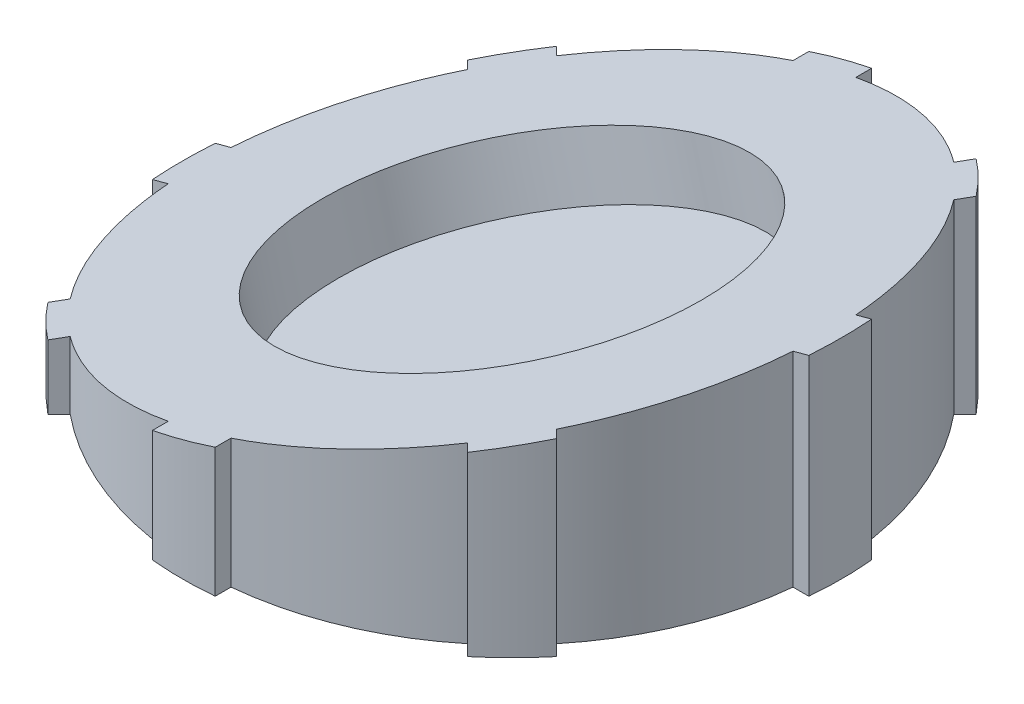
from build123d import *

# Parameters (mm, degrees)
SKETCH_1_R               = 20
EXTRUDE_1_DEPTH          = 20
EXTRUDE_2_DEPTH          = 20
PATTERN_CIRCULAR_1_COUNT = 8
CUT_EXTRUDE_1_DEPTH      = 34
SKETCH_5_R               = 12.5
CUT_EXTRUDE_2_DEPTH      = 4


with BuildPart() as part:
    # 草图1 → 凸台-拉伸1 (new body)
    with BuildSketch(Plane(origin=(0, 0, 0), x_dir=(1, 0, 0), z_dir=(0, 1, 0))):
        Circle(SKETCH_1_R)
    extrude(amount=EXTRUDE_1_DEPTH)

    # 草图3 → 凸台-拉伸2 (add)
    with BuildSketch(Plane(origin=(0, 20, 0), x_dir=(1, 0, 0), z_dir=(0, 1, 0))):
        with BuildLine():
            Line((-2, -20.90454496), (-2, 20.90454496))
            ThreePointArc((-2, 20.90454496), (0, 21), (2, 20.90454496))
            Line((2, 20.90454496), (2, -20.90454496))
            ThreePointArc((2, -20.90454496), (0, -21), (-2, -20.90454496))
        make_face()
    extrude_2 = extrude(amount=-EXTRUDE_2_DEPTH)

    # 阵列(圆周)1: 凸台-拉伸2 ×8 about axis
    pattern_circular_1_axis = Axis((0, 20, 0), (0, -1, 0))
    for i in range(1, PATTERN_CIRCULAR_1_COUNT):
        add(extrude_2.rotate(pattern_circular_1_axis, i * 360 / PATTERN_CIRCULAR_1_COUNT))

    # 草图2 → 切除-拉伸1 (cut, symmetric)
    with BuildSketch(Plane.XY):
        Polygon((-21.218882006, 2), (25.661502265, 14.561561106), (25.661502265, 41.51194957), (-21.218882006, 43.85785004), align=None)
    extrude(amount=CUT_EXTRUDE_1_DEPTH, both=True, mode=Mode.SUBTRACT)

    # 草图5 → 切除-拉伸2 (cut)
    with BuildSketch(Plane(origin=(-1.921395574, 7.170745905, 0), x_dir=(0.9659258262890681, 0.2588190451025218, 0), z_dir=(-0.2588190451025218, 0.9659258262890681, 0))):
        with Locations((1.989175071, 0)):
            Circle(SKETCH_5_R)
    extrude(amount=-CUT_EXTRUDE_2_DEPTH, mode=Mode.SUBTRACT)


solid = part.part
